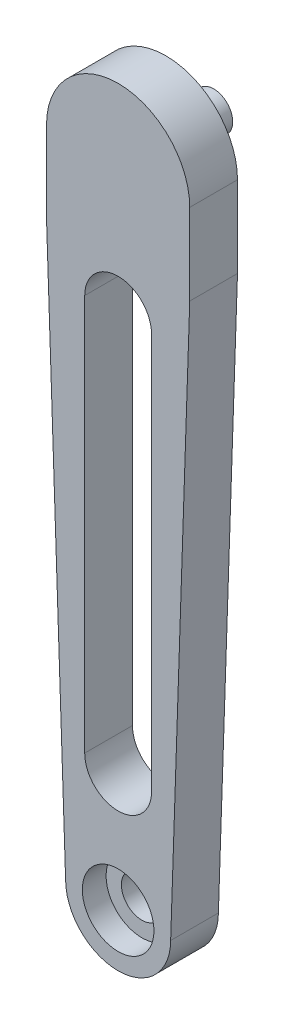
from build123d import *

# Parameters (mm, degrees)
SKETCH1_R           = 7.5
BOSS_EXTRUDE1_DEPTH = 10
SKETCH2_R           = 7.5
SKETCH2_R_2         = 4
BOSS_EXTRUDE2_DEPTH = 10
SKETCH3_R           = 4
BOSS_EXTRUDE3_DEPTH = 20
CUT_EXTRUDE2_DEPTH  = 21
SKETCH6_R           = 7.5
SKETCH6_R_2         = 4.3
BOSS_EXTRUDE4_DEPTH = 5.0216
CUT_EXTRUDE3_DEPTH  = 10


with BuildPart() as part:
    # Sketch1 → Boss-Extrude1 (new body)
    with BuildSketch(Plane.XY):
        with BuildLine():
            Line((-15, 135), (-15, 0))
            ThreePointArc((-15, 0), (0, -15), (15, 0))
            Line((15, 0), (15, 135))
            ThreePointArc((15, 135), (0, 150), (-15, 135))
        make_face()
        with Locations((0, 135)):
            Circle(SKETCH1_R, mode=Mode.SUBTRACT)
        Circle(SKETCH1_R, mode=Mode.SUBTRACT)
    extrude(amount=BOSS_EXTRUDE1_DEPTH)

    # Sketch2 → Boss-Extrude2 (add)
    with BuildSketch(Plane(origin=(0, 0, 0), x_dir=(-1, 0, 0), z_dir=(0, 0, -1))):
        with Locations((0, 135)):
            Circle(SKETCH2_R)
        with Locations((0, 135)):
            Circle(SKETCH2_R_2, mode=Mode.SUBTRACT)
    extrude(amount=-BOSS_EXTRUDE2_DEPTH)

    # Sketch3 → Boss-Extrude3 (add)
    with BuildSketch(Plane.XY.offset(10)):
        with Locations((0, 135)):
            Circle(SKETCH3_R)
    extrude(amount=-BOSS_EXTRUDE3_DEPTH)

    # Sketch5 → Cut-Extrude2 (cut, through all)
    with BuildSketch(Plane.XY.offset(10)):
        with BuildLine():
            Line((-11, 0), (-15, 118))
            Line((-15, 118), (-15, 0))
            ThreePointArc((-15, 0), (0, -15), (15, 0))
            Line((15, 0), (15, 118))
            Line((15, 118), (11, 0))
            ThreePointArc((11, 0), (0, -11), (-11, 0))
        make_face()
    extrude(amount=-CUT_EXTRUDE2_DEPTH, mode=Mode.SUBTRACT)

    # Sketch6 → Boss-Extrude4 (add)
    with BuildSketch(Plane(origin=(0, 0, 0), x_dir=(-1, 0, 0), z_dir=(0, 0, -1))):
        Circle(SKETCH6_R)
        Circle(SKETCH6_R_2, mode=Mode.SUBTRACT)
    extrude(amount=-BOSS_EXTRUDE4_DEPTH)

    # Sketch7 → Cut-Extrude3 (cut)
    with BuildSketch(Plane(origin=(0, 0, 0), x_dir=(-1, 0, 0), z_dir=(0, 0, -1))):
        with BuildLine():
            Line((-7, 108), (-7, 25))
            ThreePointArc((-7, 25), (0, 18), (7, 25))
            Line((7, 25), (7, 108))
            ThreePointArc((7, 108), (0, 115), (-7, 108))
        make_face()
    extrude(amount=-CUT_EXTRUDE3_DEPTH, mode=Mode.SUBTRACT)


solid = part.part
